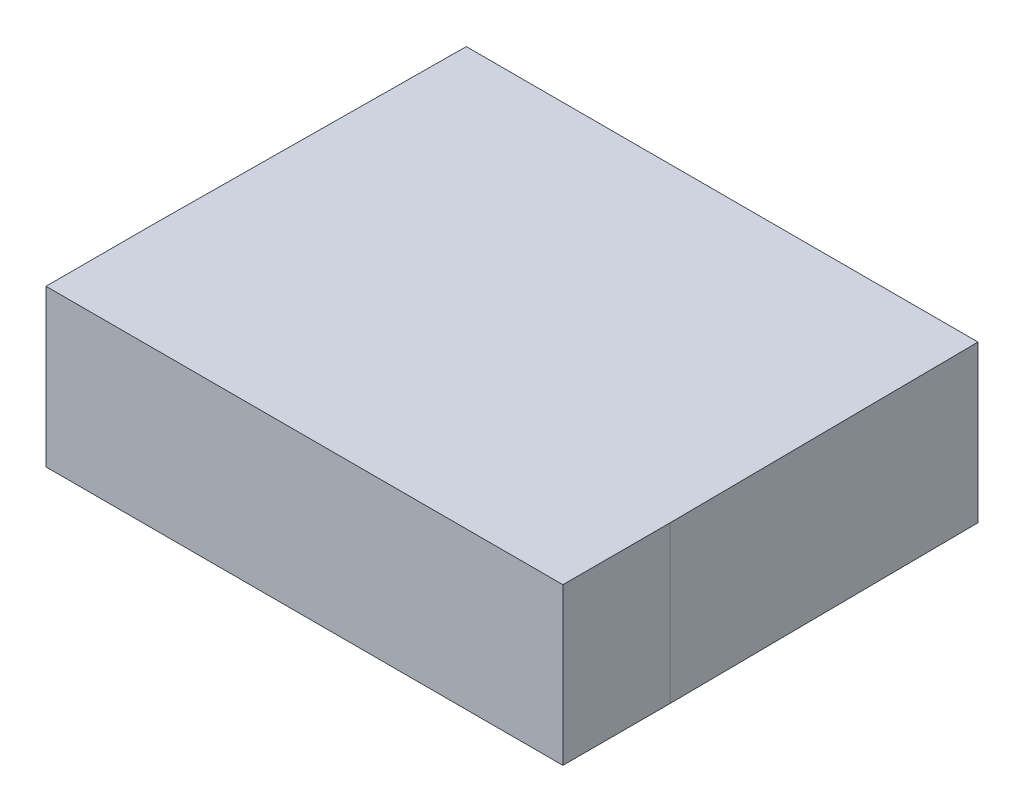
from build123d import *

# Parameters (mm, degrees)
BOSS_EXTRUDE1_DEPTH = 2.9972


with BuildPart() as part:
    # Sketch1 → Boss-Extrude1 (new body)
    with BuildSketch(Plane(origin=(0, 0, 0), x_dir=(1, 0, 0), z_dir=(0, 1, 0))):
        Polygon((-4.9, 0), (4.9, 0), (4.95, -5.95), (4.95, -8), (-4.95, -8), (-4.95, -5.95), align=None)
    extrude(amount=BOSS_EXTRUDE1_DEPTH)


solid = part.part
